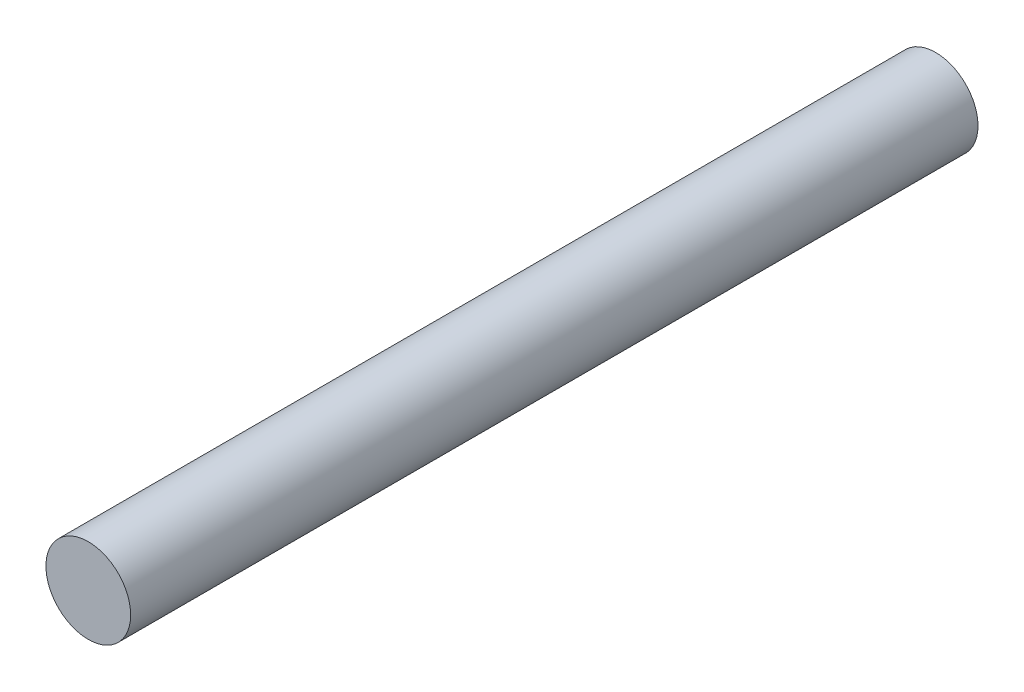
from build123d import *

# Parameters (mm, degrees)
SKETCH_1_R      = 1.5
EXTRUDE_1_DEPTH = 30


with BuildPart() as part:
    # ｽｹｯﾁ1 → ﾎﾞｽ - 押し出し1 (new body)
    with BuildSketch(Plane.XY):
        Circle(SKETCH_1_R)
    extrude(amount=EXTRUDE_1_DEPTH)


solid = part.part
